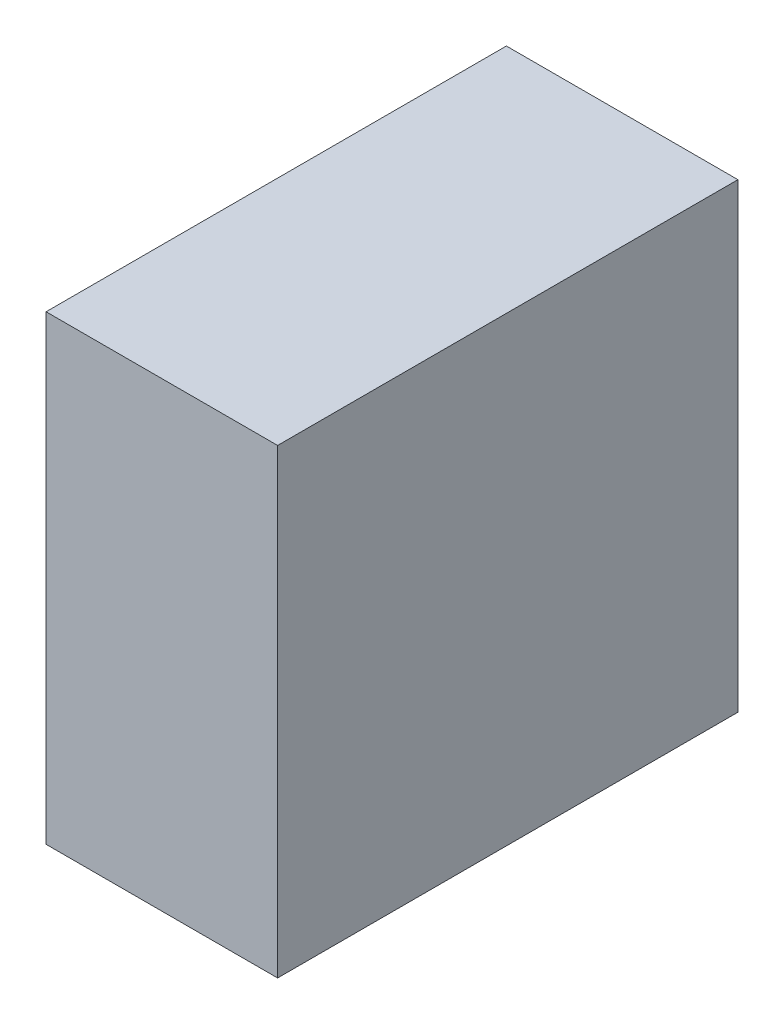
from build123d import *

# Parameters (mm, degrees)
SKETCH1_W           = 504
SKETCH1_H           = 1004
SKETCH1_W_2         = 500
SKETCH1_H_2         = 1000
BOSS_EXTRUDE1_DEPTH = 1000
SKETCH2_W           = 504
SKETCH2_H           = 1004
BOSS_EXTRUDE2_DEPTH = 2


with BuildPart() as part:
    # Sketch1 → Boss-Extrude1 (new body)
    with BuildSketch(Plane.XY):
        with Locations((250, 500)):
            Rectangle(SKETCH1_W, SKETCH1_H)
        with Locations((250, 500)):
            Rectangle(SKETCH1_W_2, SKETCH1_H_2, mode=Mode.SUBTRACT)
    extrude(amount=BOSS_EXTRUDE1_DEPTH)

    # Sketch2 → Boss-Extrude2 (add)
    with BuildSketch(Plane.XY.offset(1000)):
        with Locations((250, 500)):
            Rectangle(SKETCH2_W, SKETCH2_H)
    extrude(amount=BOSS_EXTRUDE2_DEPTH)


solid = part.part
